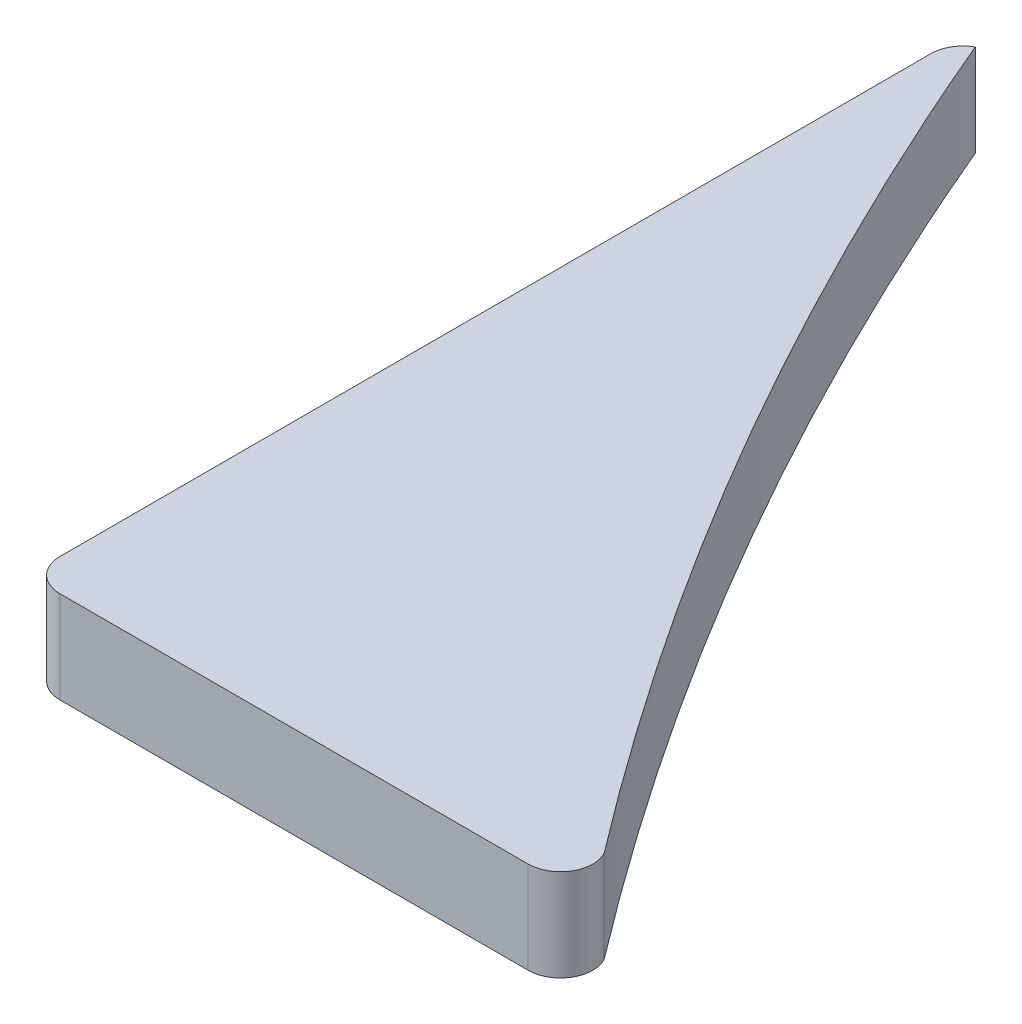
from build123d import *

# Parameters (mm, degrees)
BOSS_EXTRUDE1_DEPTH = 5.7


with BuildPart() as part:
    # Sketch1 → Boss-Extrude1 (new body)
    with BuildSketch(Plane(origin=(0, 0, 0), x_dir=(1, 0, 0), z_dir=(0, 1, 0))):
        with BuildLine():
            Line((0, 2), (0, 55.935985031))
            ThreePointArc((0, 55.935985031), (0.272628254, 56.944045968), (1.016186852, 57.677281011))
            add(Edge.make_bspline(
                [(1.016186852, 57.677281011), (13.390937023, 28.412904977), (32.762191576, 2.945875706)],
                knots=[0, 0, 0, 1, 1, 1], degree=2))
            ThreePointArc((32.762191576, 2.945875706), (32.716355355, 0.973294446), (31, 0))
            Line((31, 0), (2, 0))
            ThreePointArc((2, 0), (0.585786438, 0.585786438), (0, 2))
        make_face()
    extrude(amount=BOSS_EXTRUDE1_DEPTH)


solid = part.part
